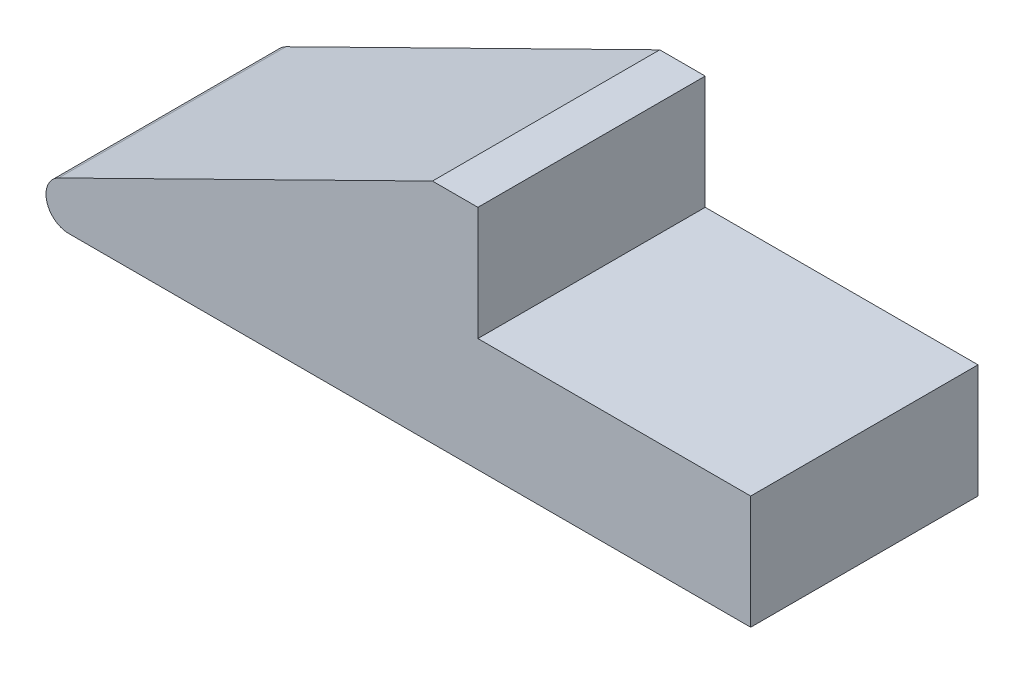
from build123d import *

# Parameters (mm, degrees)
BASE_EXTRUDE_DEPTH = 5


with BuildPart() as part:
    # Sketch1 → Base-Extrude (new body, symmetric)
    with BuildSketch(Plane.XY):
        with BuildLine():
            Line((-0.442055564, 1.896987669), (16, 10))
            Line((16, 10), (18, 10))
            Line((18, 10), (18, 5))
            Line((18, 5), (30, 5))
            Line((30, 5), (30, 0))
            Line((30, 0), (0, 0))
            ThreePointArc((0, 0), (-0.973906481, 0.773050302), (-0.442055564, 1.896987669))
        make_face()
    extrude(amount=BASE_EXTRUDE_DEPTH, both=True)


solid = part.part
